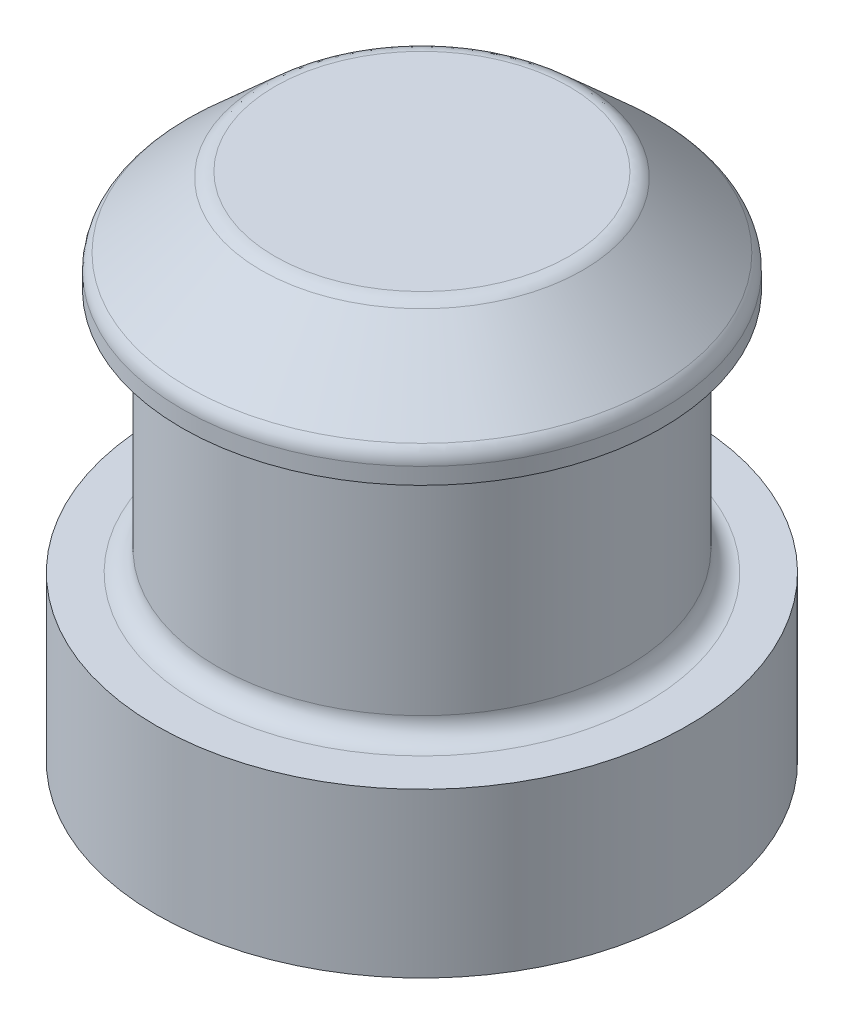
from build123d import *

# Parameters (mm, degrees)
SKETCH1_R           = 2.6
BOSS_EXTRUDE1_DEPTH = 1.6
SKETCH2_R           = 2
BOSS_EXTRUDE2_DEPTH = 2.4
SKETCH3_R           = 2.35
BOSS_EXTRUDE3_DEPTH = 1
CHAMFER1_SIZE       = 0.75
CHAMFER1_SIZE2      = 0.832959386
FILLET1_R           = 0.2
SCALE1_SCALE        = 1.15


with BuildPart() as part:
    # Sketch1 → Boss-Extrude1 (new body)
    with BuildSketch(Plane(origin=(0, 0, 0), x_dir=(1, 0, 0), z_dir=(0, 1, 0))):
        Circle(SKETCH1_R)
    extrude(amount=BOSS_EXTRUDE1_DEPTH)

    # Sketch2 → Boss-Extrude2 (add)
    with BuildSketch(Plane(origin=(0, 1.6, 0), x_dir=(1, 0, 0), z_dir=(0, 1, 0))):
        Circle(SKETCH2_R)
    extrude(amount=BOSS_EXTRUDE2_DEPTH)

    # Sketch3 → Boss-Extrude3 (add)
    with BuildSketch(Plane(origin=(0, 4, 0), x_dir=(1, 0, 0), z_dir=(0, 1, 0))):
        Circle(SKETCH3_R)
    extrude(amount=BOSS_EXTRUDE3_DEPTH)

    # Chamfer1
    chamfer1_edges = [part.edges().sort_by_distance(p)[0] for p in [
        (-2.35, 5, 0),
    ]]
    chamfer1_side = [part.faces().sort_by_distance(p)[0] for p in [
        (-2.35, 4.5, 0),
    ]]
    chamfer(chamfer1_edges, length=CHAMFER1_SIZE, length2=CHAMFER1_SIZE2, reference=chamfer1_side[0])

    # Fillet1
    fillet1_edges = [part.edges().sort_by_distance(p)[0] for p in [
        (-1.517040614, 5, 0),
        (-2.35, 4.25, 0),
        (-2, 1.6, 0),
    ]]
    fillet(fillet1_edges, radius=FILLET1_R)


with BuildPart() as part_1:
    # Scale1: scaled about (-4.4e-08, 2.199734094, 0)
    add(part.part.scale(SCALE1_SCALE).moved(Location((7e-09, -0.329960114, 0))))


solid = part_1.part
